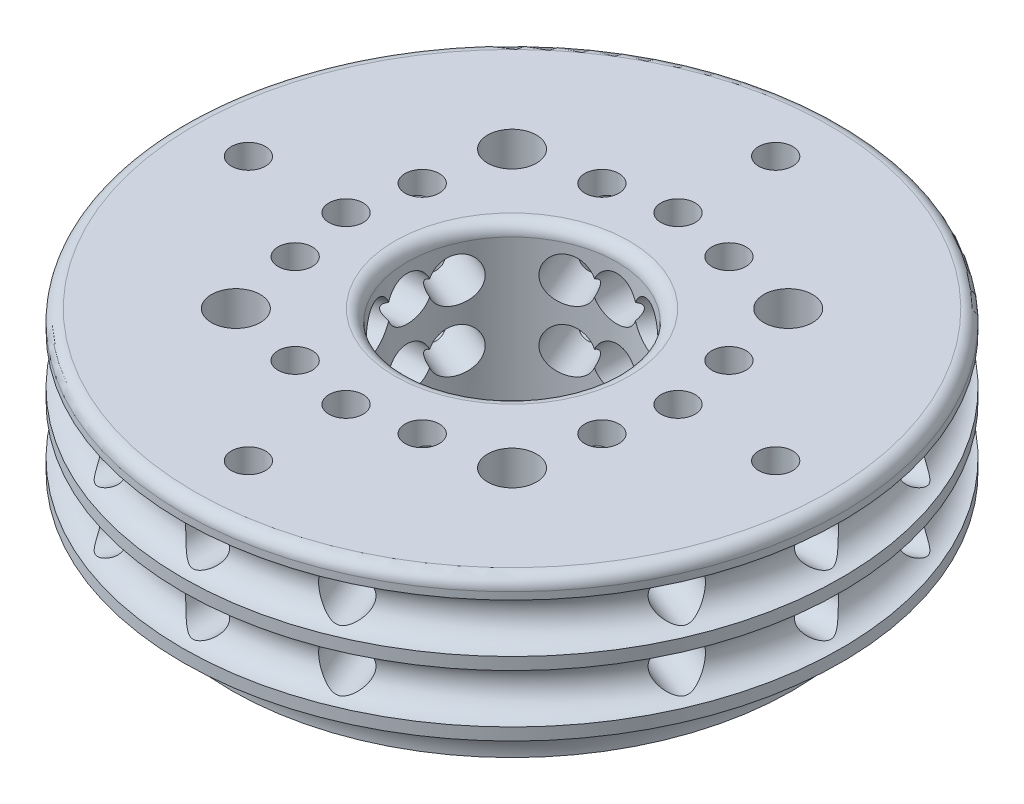
from build123d import *

# Parameters (mm, degrees)
SKETCH1_R               = 13.5
SKETCH1_R_2             = 4.3
SKETCH1_R_3             = 1
BOSS_EXTRUDE1_DEPTH     = 7
SKETCH2_R               = 5
BOSS_EXTRUDE2_DEPTH     = 3.5
SKETCH3_R               = 10.325
CUT_EXTRUDE1_DEPTH      = 1.5
CUT_SWEEP1_PROFILE_R    = 1
CUT_SWEEP2_PROFILE_R    = 1
CHAMFER1_SIZE           = 2
SKETCH40_R              = 2.55
CUT_EXTRUDE3_DEPTH      = 2
SKETCH100_R             = 2
SKETCH108_R             = 2.55
SKETCH108_R_2           = 1
BOSS_EXTRUDE3_DEPTH     = 2.8
SKETCH109_R             = 13.5
SKETCH109_R_2           = 4.3
SKETCH109_R_3           = 2.55
BOSS_EXTRUDE4_DEPTH     = 0.8
SKETCH164_R             = 4.3
CUT_EXTRUDE6_DEPTH      = 1.8
CUT_EXTRUDE6_DEPTH_BACK = 8
CUT_SWEEP4_PROFILE_R    = 0.9
CUT_SWEEP5_PROFILE_R    = 0.9
CUT_SWEEP6_PROFILE_R    = 0.9
CUT_SWEEP7_PROFILE_R    = 0.9
CUT_SWEEP8_PROFILE_R    = 0.9
CUT_SWEEP9_PROFILE_R    = 0.9
SKETCH285_R             = 0.7
CUT_EXTRUDE7_DEPTH      = 5.5
FILLET1_R               = 0.5
SKETCH286_R             = 0.7
CUT_EXTRUDE8_DEPTH      = 5


with BuildPart() as part:
    # Sketch1 → Boss-Extrude1 (new body)
    with BuildSketch(Plane(origin=(0, 0, 0), x_dir=(1, 0, 0), z_dir=(0, 1, 0))):
        Circle(SKETCH1_R)
        Circle(SKETCH1_R_2, mode=Mode.SUBTRACT)
        with Locations((-5.656854249, 5.656854249)):
            Circle(SKETCH1_R_3, mode=Mode.SUBTRACT)
        with Locations((5.656854249, 5.656854249)):
            Circle(SKETCH1_R_3, mode=Mode.SUBTRACT)
        with Locations((5.656854249, -5.656854249)):
            Circle(SKETCH1_R_3, mode=Mode.SUBTRACT)
        with Locations((-5.656854249, -5.656854249)):
            Circle(SKETCH1_R_3, mode=Mode.SUBTRACT)
    extrude(amount=BOSS_EXTRUDE1_DEPTH)

    # Sketch2 → Boss-Extrude2 (add)
    with BuildSketch(Plane(origin=(0, 7, 0), x_dir=(1, 0, 0), z_dir=(0, 1, 0))):
        Circle(SKETCH2_R)
    extrude(amount=-BOSS_EXTRUDE2_DEPTH)

    # Sketch3 → Cut-Extrude1 (cut)
    with BuildSketch(Plane.XZ):
        Circle(SKETCH3_R)
    extrude(amount=-CUT_EXTRUDE1_DEPTH, mode=Mode.SUBTRACT)

    # Cut-Sweep1: sweep along a path in Sketch5
    with BuildLine(Plane(origin=(0, 3.5, 0), x_dir=(1, 0, 0), z_dir=(0, 1, 0))) as cut_sweep1_path:
        CenterArc((0, 0), 13.5, 0, 360)
    # Cut-Sweep1 profile (on start of the path) → Cut-Sweep1 (sweep, cut)
    with BuildSketch(Plane(origin=(13.5, 3.5, 0), x_dir=(-1, 0, 0), z_dir=(0, 0, -1))):
        Circle(CUT_SWEEP1_PROFILE_R)
    sweep(path=cut_sweep1_path.line, mode=Mode.SUBTRACT)

    # Cut-Sweep2: sweep along a path in Sketch99
    with BuildLine(Plane(origin=(0, 6, 0), x_dir=(1, 0, 0), z_dir=(0, 1, 0))) as cut_sweep2_path:
        CenterArc((0, 0), 13.5, 0, 360)
    # Cut-Sweep2 profile (on start of the path) → Cut-Sweep2 (sweep, cut)
    with BuildSketch(Plane(origin=(13.5, 6, 0), x_dir=(-1, 0, 0), z_dir=(0, 0, -1))):
        Circle(CUT_SWEEP2_PROFILE_R)
    sweep(path=cut_sweep2_path.line, mode=Mode.SUBTRACT)

    # Chamfer1
    chamfer1_edges = [part.edges().sort_by_distance(p)[0] for p in [
        (-13.5, 0, 0),
    ]]
    chamfer(chamfer1_edges, length=CHAMFER1_SIZE)

    # Sketch40 → Cut-Extrude3 (cut)
    with BuildSketch(Plane(origin=(0, 7, 0), x_dir=(1, 0, 0), z_dir=(0, 1, 0))):
        with Locations((-5.656854249, -5.656854249)):
            Circle(SKETCH40_R)
        with Locations((-5.656854249, 5.656854249)):
            Circle(SKETCH40_R)
        with Locations((5.656854249, 5.656854249)):
            Circle(SKETCH40_R)
        with Locations((5.656854249, -5.656854249)):
            Circle(SKETCH40_R)
    extrude(amount=-CUT_EXTRUDE3_DEPTH, mode=Mode.SUBTRACT)

    # Cut-Sweep3: sweep along a path in Sketch101
    with BuildLine(Plane(origin=(0, 0, 0), x_dir=(1, 0, 0), z_dir=(0, 1, 0))) as cut_sweep3_path:
        CenterArc((0, 0), 13.5, 0, 360)
    # Sketch100 → Cut-Sweep3 (sweep, cut)
    with BuildSketch(Plane(origin=(0, 0, 0), x_dir=(0, 0, -1), z_dir=(1, 0, 0))):
        with Locations((-13.5, 0)):
            Circle(SKETCH100_R)
    sweep(path=cut_sweep3_path.line, mode=Mode.SUBTRACT)

    # Sketch108 → Boss-Extrude3 (add)
    with BuildSketch(Plane(origin=(0, 5, 0), x_dir=(1, 0, 0), z_dir=(0, 1, 0))):
        with Locations((-5.656854249, 5.656854249)):
            Circle(SKETCH108_R)
        with Locations((-5.656854249, 5.656854249)):
            Circle(SKETCH108_R_2, mode=Mode.SUBTRACT)
        with Locations((-5.656854249, -5.656854249)):
            Circle(SKETCH108_R)
        with Locations((-5.656854249, -5.656854249)):
            Circle(SKETCH108_R_2, mode=Mode.SUBTRACT)
        with Locations((5.656854249, -5.656854249)):
            Circle(SKETCH108_R)
        with Locations((5.656854249, -5.656854249)):
            Circle(SKETCH108_R_2, mode=Mode.SUBTRACT)
        with Locations((5.656854249, 5.656854249)):
            Circle(SKETCH108_R)
        with Locations((5.656854249, 5.656854249)):
            Circle(SKETCH108_R_2, mode=Mode.SUBTRACT)
    extrude(amount=BOSS_EXTRUDE3_DEPTH)

    # Sketch109 → Boss-Extrude4 (add)
    with BuildSketch(Plane(origin=(0, 7, 0), x_dir=(1, 0, 0), z_dir=(0, 1, 0))):
        Circle(SKETCH109_R)
        Circle(SKETCH109_R_2, mode=Mode.SUBTRACT)
        with Locations((5.656854249, -5.656854249)):
            Circle(SKETCH109_R_3, mode=Mode.SUBTRACT)
        with Locations((-5.656854249, -5.656854249)):
            Circle(SKETCH109_R_3, mode=Mode.SUBTRACT)
        with Locations((-5.656854249, 5.656854249)):
            Circle(SKETCH109_R_3, mode=Mode.SUBTRACT)
        with Locations((5.656854249, 5.656854249)):
            Circle(SKETCH109_R_3, mode=Mode.SUBTRACT)
    extrude(amount=BOSS_EXTRUDE4_DEPTH)

    # Sketch164 → Cut-Extrude6 (cut, two sides)
    with BuildSketch(Plane(origin=(0, 7, 0), x_dir=(1, 0, 0), z_dir=(0, 1, 0))) as cut_extrude6_sk:
        Circle(SKETCH164_R)
    extrude(amount=CUT_EXTRUDE6_DEPTH, mode=Mode.SUBTRACT)
    extrude(cut_extrude6_sk.sketch, amount=-CUT_EXTRUDE6_DEPTH_BACK, mode=Mode.SUBTRACT)

    # Cut-Sweep4: sweep along a path in Sketch167
    with BuildLine(Plane(origin=(0, 3.5, 0), x_dir=(1, 0, 0), z_dir=(0, 1, 0))) as cut_sweep4_path:
        Line((0, -13.5), (0, 13.5))
    # Cut-Sweep4 profile (on start of the path) → Cut-Sweep4 (sweep, cut)
    with BuildSketch(Plane(origin=(0, 3.5, 13.5), x_dir=(-1, 0, 0), z_dir=(0, 0, -1))):
        Circle(CUT_SWEEP4_PROFILE_R)
    cut_sweep4 = sweep(path=cut_sweep4_path.line, mode=Mode.SUBTRACT)

    # Cut-Sweep5: sweep along a path in Sketch208
    with BuildLine(Plane(origin=(0, 3.5, 0), x_dir=(1, 0, 0), z_dir=(0, 1, 0))) as cut_sweep5_path:
        Line((5.166226337, 12.472373689), (-5.166226337, -12.472373689))
    # Cut-Sweep5 profile (on start of the path) → Cut-Sweep5 (sweep, cut)
    with BuildSketch(Plane(origin=(5.166226337, 3.5, -12.472373689), x_dir=(0.923879533, 0, 0.382683432), z_dir=(-0.382683432, 0, 0.923879533))):
        Circle(CUT_SWEEP5_PROFILE_R)
    cut_sweep5 = sweep(path=cut_sweep5_path.line, mode=Mode.SUBTRACT)

    # Cut-Sweep6: sweep along a path in Sketch221
    with BuildLine(Plane(origin=(0, 3.5, 0), x_dir=(1, 0, 0), z_dir=(0, 1, 0))) as cut_sweep6_path:
        Line((-12.472373689, -5.166226337), (12.472373689, 5.166226337))
    # Cut-Sweep6 profile (on start of the path) → Cut-Sweep6 (sweep, cut)
    with BuildSketch(Plane(origin=(-12.472373689, 3.5, 5.166226337), x_dir=(0.382683432, 0, 0.923879533), z_dir=(0.923879533, 0, -0.382683432))):
        Circle(CUT_SWEEP6_PROFILE_R)
    cut_sweep6 = sweep(path=cut_sweep6_path.line, mode=Mode.SUBTRACT)

    # Cut-Sweep7: sweep along a path in Sketch234
    with BuildLine(Plane(origin=(0, 3.5, 0), x_dir=(1, 0, 0), z_dir=(0, 1, 0))) as cut_sweep7_path:
        Line((13.5, 0), (-13.5, 0))
    # Cut-Sweep7 profile (on start of the path) → Cut-Sweep7 (sweep, cut)
    with BuildSketch(Plane(origin=(13.5, 3.5, 0), x_dir=(0, 0, -1), z_dir=(-1, 0, 0))):
        Circle(CUT_SWEEP7_PROFILE_R)
    cut_sweep7 = sweep(path=cut_sweep7_path.line, mode=Mode.SUBTRACT)

    # Cut-Sweep8: sweep along a path in Sketch247
    with BuildLine(Plane(origin=(0, 3.5, 0), x_dir=(1, 0, 0), z_dir=(0, 1, 0))) as cut_sweep8_path:
        Line((12.472373689, -5.166226337), (-12.472373689, 5.166226337))
    # Cut-Sweep8 profile (on start of the path) → Cut-Sweep8 (sweep, cut)
    with BuildSketch(Plane(origin=(12.472373689, 3.5, 5.166226337), x_dir=(0.382683432, 0, -0.923879533), z_dir=(-0.923879533, 0, -0.382683432))):
        Circle(CUT_SWEEP8_PROFILE_R)
    cut_sweep8 = sweep(path=cut_sweep8_path.line, mode=Mode.SUBTRACT)

    # Cut-Sweep9: sweep along a path in Sketch260
    with BuildLine(Plane(origin=(0, 3.5, 0), x_dir=(1, 0, 0), z_dir=(0, 1, 0))) as cut_sweep9_path:
        Line((5.166226337, -12.472373689), (-5.166226337, 12.472373689))
    # Cut-Sweep9 profile (on start of the path) → Cut-Sweep9 (sweep, cut)
    with BuildSketch(Plane(origin=(5.166226337, 3.5, 12.472373689), x_dir=(-0.923879533, 0, 0.382683432), z_dir=(-0.382683432, 0, -0.923879533))):
        Circle(CUT_SWEEP9_PROFILE_R)
    cut_sweep9 = sweep(path=cut_sweep9_path.line, mode=Mode.SUBTRACT)

    # Mirror1: Cut-Sweep4, Cut-Sweep5, Cut-Sweep6, Cut-Sweep7, Cut-Sweep8, Cut-Sweep9 across plane
    add(cut_sweep4.mirror(Plane.ZX.offset(4.75)), mode=Mode.SUBTRACT)
    add(cut_sweep5.mirror(Plane.ZX.offset(4.75)), mode=Mode.SUBTRACT)
    add(cut_sweep6.mirror(Plane.ZX.offset(4.75)), mode=Mode.SUBTRACT)
    add(cut_sweep7.mirror(Plane.ZX.offset(4.75)), mode=Mode.SUBTRACT)
    add(cut_sweep8.mirror(Plane.ZX.offset(4.75)), mode=Mode.SUBTRACT)
    add(cut_sweep9.mirror(Plane.ZX.offset(4.75)), mode=Mode.SUBTRACT)

    # Sketch285 → Cut-Extrude7 (cut)
    with BuildSketch(Plane(origin=(0, 7.8, 0), x_dir=(1, 0, 0), z_dir=(0, 1, 0))):
        with Locations((0, -6.8)):
            Circle(SKETCH285_R)
        with Locations((-2.60224734, -6.282380821)):
            Circle(SKETCH285_R)
        with Locations((-6.282380821, -2.60224734)):
            Circle(SKETCH285_R)
        with Locations((-6.8, 0)):
            Circle(SKETCH285_R)
        with Locations((-6.282380821, 2.60224734)):
            Circle(SKETCH285_R)
        with Locations((-2.60224734, 6.282380821)):
            Circle(SKETCH285_R)
        with Locations((0, 6.8)):
            Circle(SKETCH285_R)
        with Locations((2.60224734, 6.282380821)):
            Circle(SKETCH285_R)
        with Locations((6.282380821, 2.60224734)):
            Circle(SKETCH285_R)
        with Locations((6.8, 0)):
            Circle(SKETCH285_R)
        with Locations((6.282380821, -2.60224734)):
            Circle(SKETCH285_R)
        with Locations((2.60224734, -6.282380821)):
            Circle(SKETCH285_R)
    extrude(amount=-CUT_EXTRUDE7_DEPTH, mode=Mode.SUBTRACT)

    # Fillet1
    fillet1_edges = [part.edges().sort_by_distance(p)[0] for p in [
        (-4.3, 7.8, 0),
        (-13.5, 7.8, 0),
    ]]
    fillet(fillet1_edges, radius=FILLET1_R)

    # Sketch286 → Cut-Extrude8 (cut)
    with BuildSketch(Plane(origin=(0, 7.8, 0), x_dir=(1, 0, 0), z_dir=(0, 1, 0))):
        with Locations((0, 10.8)):
            Circle(SKETCH286_R)
        with Locations((10.8, 0)):
            Circle(SKETCH286_R)
        with Locations((0, -10.8)):
            Circle(SKETCH286_R)
        with Locations((-10.8, 0)):
            Circle(SKETCH286_R)
    extrude(amount=-CUT_EXTRUDE8_DEPTH, mode=Mode.SUBTRACT)


solid = part.part
